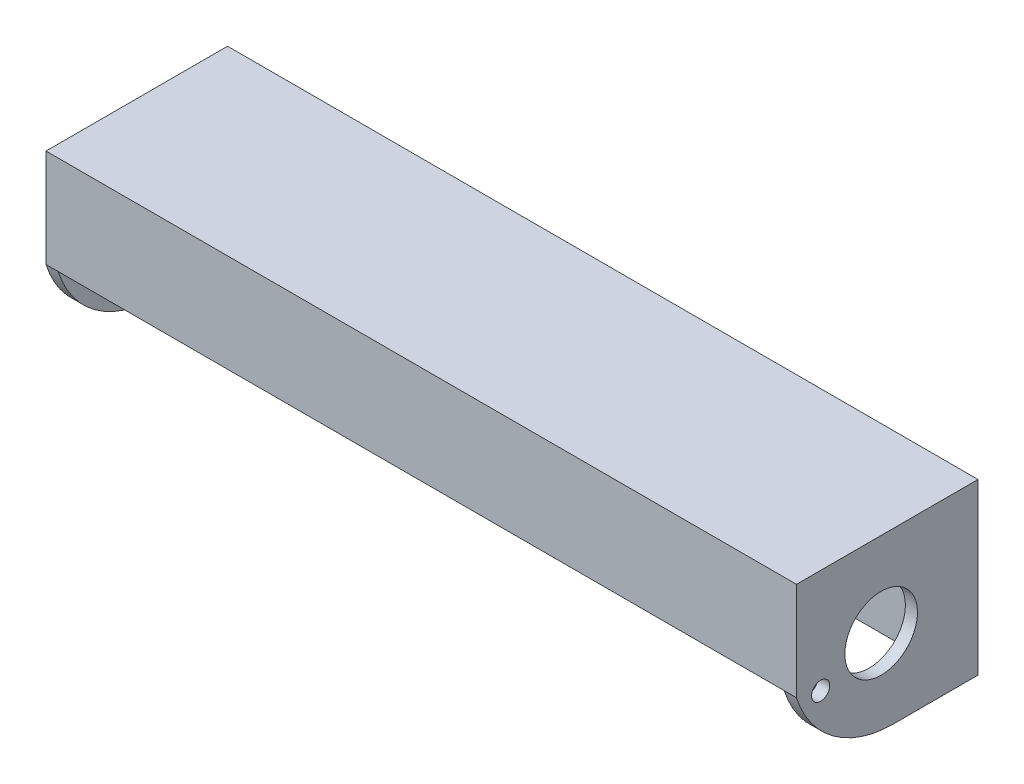
from build123d import *

# Parameters (mm, degrees)
SKETCH1_W           = 1524
SKETCH1_H           = 355.6
BOSS_EXTRUDE1_DEPTH = 25.4
BOSS_EXTRUDE5_DEPTH = 25.4
BOSS_EXTRUDE6_DEPTH = 762
SKETCH7_R           = 76.2
CUT_EXTRUDE1_DEPTH  = 1575.8
SKETCH8_R           = 19.05
CUT_EXTRUDE2_DEPTH  = 1575.8


with BuildPart() as part:
    # Sketch1 → Boss-Extrude1 (new body)
    with BuildSketch(Plane.XY):
        with Locations((737.21023766, 170.176599634)):
            Rectangle(SKETCH1_W, SKETCH1_H)
    extrude(amount=BOSS_EXTRUDE1_DEPTH)

    # Sketch5 → Boss-Extrude5 (add)
    with BuildSketch(Plane.ZY.offset(24.78976234)):
        with BuildLine():
            Line((0, 347.976599634), (381, 347.976599634))
            Line((381, 347.976599634), (381, 141.861776851))
            ThreePointArc((381, 141.861776851), (303.930942088, 33.773491198), (177.8, -7.623400366))
            Line((177.8, -7.623400366), (0, -7.623400366))
            Line((0, -7.623400366), (0, 347.976599634))
        make_face()
    boss_extrude5 = extrude(amount=BOSS_EXTRUDE5_DEPTH)

    # Sketch6 → Boss-Extrude6 (add)
    with BuildSketch(Plane(origin=(-24.78976234, 0, 0), x_dir=(0, 0, -1), z_dir=(1, 0, 0))):
        Polygon((-25.4, 347.976599634), (-381, 347.976599634), (-381, 141.861776851), (-368.3, 141.861776851), (-368.3, 335.276599634), (-25.4, 335.276599634), align=None)
    boss_extrude6 = extrude(amount=BOSS_EXTRUDE6_DEPTH)

    # Mirror2: Boss-Extrude5, Boss-Extrude6 across plane
    add(boss_extrude5.mirror(Plane(origin=(737.21023766, 0, 0), x_dir=(0, 0, 1), z_dir=(1, 0, 0))))
    add(boss_extrude6.mirror(Plane(origin=(737.21023766, 0, 0), x_dir=(0, 0, 1), z_dir=(1, 0, 0))))

    # Sketch7 → Cut-Extrude1 (cut, through all)
    with BuildSketch(Plane.ZY.offset(50.18976234)):
        with Locations((203.2, 170.176599634)):
            Circle(SKETCH7_R)
    extrude(amount=-CUT_EXTRUDE1_DEPTH, mode=Mode.SUBTRACT)

    # Sketch8 → Cut-Extrude2 (cut, through all)
    with BuildSketch(Plane.ZY.offset(50.18976234)):
        with Locations((330.2, 129.161776851)):
            Circle(SKETCH8_R)
    extrude(amount=-CUT_EXTRUDE2_DEPTH, mode=Mode.SUBTRACT)


solid = part.part
